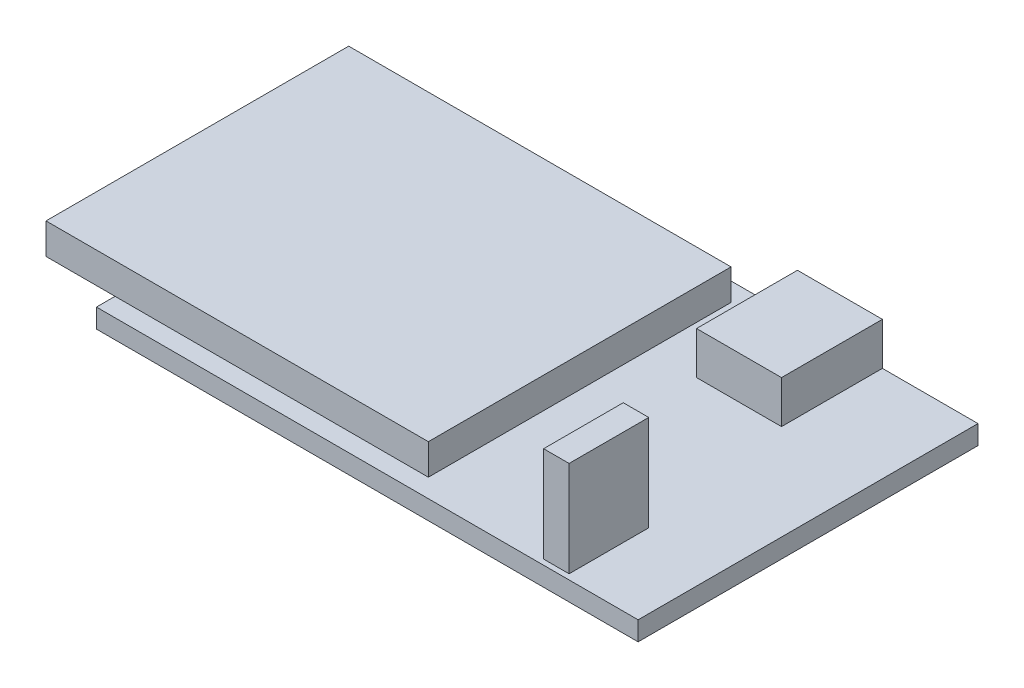
from build123d import *

# Parameters (mm, degrees)
SKETCH1_W           = 51
SKETCH1_H           = 32
BOSS_EXTRUDE1_DEPTH = 1.8
SKETCH2_W           = 36
SKETCH2_H           = 28.5
BOSS_EXTRUDE2_DEPTH = 2.9
SKETCH3_W           = 2.4
SKETCH3_H           = 7.5
BOSS_EXTRUDE3_DEPTH = 9
SKETCH4_W           = 8
SKETCH4_H           = 9.5
BOSS_EXTRUDE4_DEPTH = 4


with BuildPart() as part:
    # Sketch1 → Boss-Extrude1 (new body)
    with BuildSketch(Plane(origin=(0, 0, 0), x_dir=(1, 0, 0), z_dir=(0, 1, 0))):
        with Locations((25.5, 16)):
            Rectangle(SKETCH1_W, SKETCH1_H)
    extrude(amount=BOSS_EXTRUDE1_DEPTH)

    # Sketch2 → Boss-Extrude2 (add)
    with BuildSketch(Plane(origin=(0, 1.8, 0), x_dir=(1, 0, 0), z_dir=(0, 1, 0))):
        with Locations((11.5, 16)):
            Rectangle(SKETCH2_W, SKETCH2_H)
    extrude(amount=BOSS_EXTRUDE2_DEPTH)

    # Sketch3 → Boss-Extrude3 (add)
    with BuildSketch(Plane(origin=(0, 1.8, 0), x_dir=(1, 0, 0), z_dir=(0, 1, 0))):
        with Locations((42.8, 4.25)):
            Rectangle(SKETCH3_W, SKETCH3_H)
    extrude(amount=BOSS_EXTRUDE3_DEPTH)

    # Sketch4 → Boss-Extrude4 (add)
    with BuildSketch(Plane(origin=(0, 1.8, 0), x_dir=(1, 0, 0), z_dir=(0, 1, 0))):
        with Locations((38, 27.25)):
            Rectangle(SKETCH4_W, SKETCH4_H)
    extrude(amount=BOSS_EXTRUDE4_DEPTH)


solid = part.part
